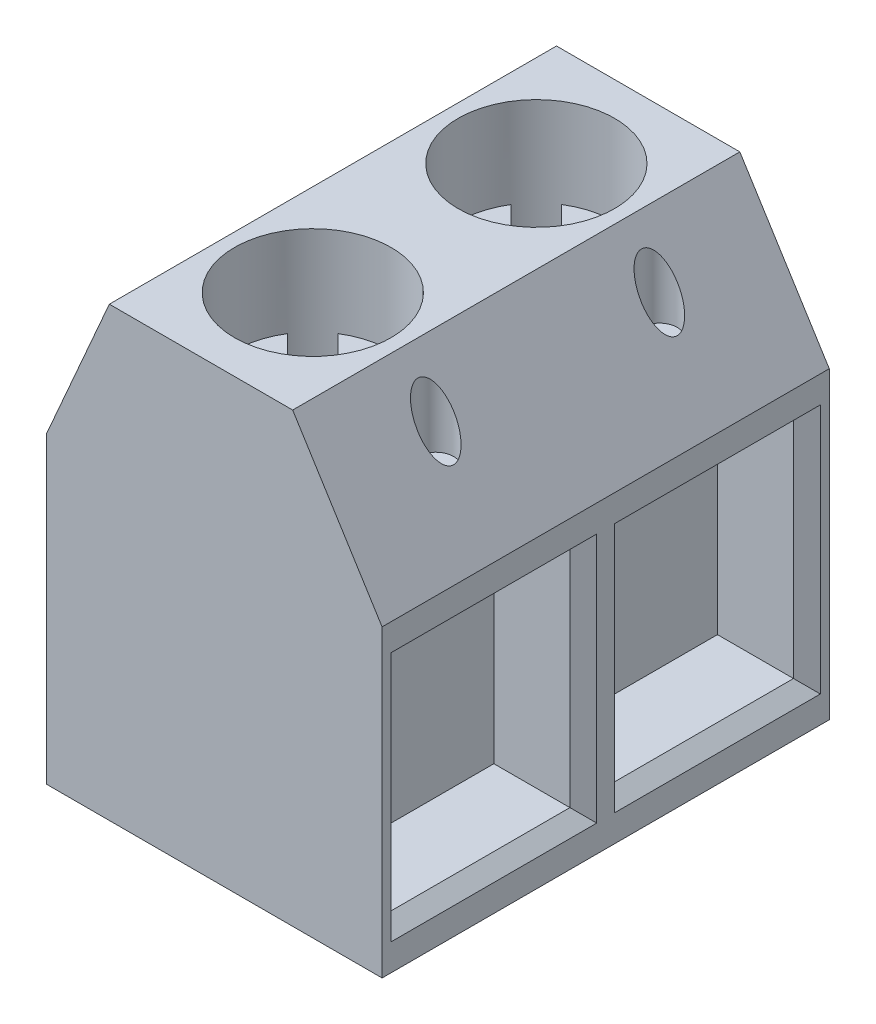
from build123d import *

# Parameters (mm, degrees)
BOSS_EXTRUDE1_DEPTH = 5
SKETCH2_W           = 1
SKETCH2_H           = 1
BOSS_EXTRUDE2_DEPTH = 1
SKETCH3_W           = 4
SKETCH3_H           = 5
CUT_EXTRUDE1_DEPTH  = 2
SKETCH4_R           = 1.75
SKETCH4_R_2         = 0.4
CUT_EXTRUDE2_DEPTH  = 2
CUT_EXTRUDE3_DEPTH  = 0.5
CHAMFER1_SIZE       = 0.3


with BuildPart() as part:
    # Sketch1 → Boss-Extrude1 (new body, symmetric)
    with BuildSketch(Plane.XY):
        Polygon((-3.75, 0), (3.75, 0), (3.75, 6.8), (1.75, 10), (-2.35, 10), (-3.75, 6.8), align=None)
    extrude(amount=BOSS_EXTRUDE1_DEPTH, both=True)

    # Sketch2 → Boss-Extrude2 (add)
    with BuildSketch(Plane.XZ):
        with Locations((0.45, 2.5)):
            Rectangle(SKETCH2_W, SKETCH2_H)
        with Locations((0.45, -2.5)):
            Rectangle(SKETCH2_W, SKETCH2_H)
    extrude(amount=BOSS_EXTRUDE2_DEPTH)

    # Sketch3 → Cut-Extrude1 (cut)
    with BuildSketch(Plane(origin=(3.75, 0, 0), x_dir=(0, 0, -1), z_dir=(1, 0, 0))):
        with Locations((-2.5, 3.4)):
            Rectangle(SKETCH3_W, SKETCH3_H)
        with Locations((2.5, 3.4)):
            Rectangle(SKETCH3_W, SKETCH3_H)
    extrude(amount=-CUT_EXTRUDE1_DEPTH, mode=Mode.SUBTRACT)

    # Sketch4 → Cut-Extrude2 (cut)
    with BuildSketch(Plane(origin=(0, 10, 0), x_dir=(1, 0, 0), z_dir=(0, 1, 0))):
        with Locations((-0.3, 2.5)):
            Circle(SKETCH4_R)
        with Locations((-0.3, -2.5)):
            Circle(SKETCH4_R)
        with Locations((2.45, 2.5)):
            Circle(SKETCH4_R_2)
        with Locations((2.45, -2.5)):
            Circle(SKETCH4_R_2)
        with Locations((-3.05, 2.5)):
            Circle(SKETCH4_R_2)
        with Locations((-3.05, -2.5)):
            Circle(SKETCH4_R_2)
    extrude(amount=-CUT_EXTRUDE2_DEPTH, mode=Mode.SUBTRACT)

    # Sketch5 → Cut-Extrude3 (cut)
    with BuildSketch(Plane(origin=(0, 8, 0), x_dir=(1, 0, 0), z_dir=(0, 1, 0))):
        with BuildLine():
            Line((-1.221836, -1.012479), (-0.3, -1.934315))
            Line((-0.3, -1.934315), (0.124264, -1.510051))
            Line((0.124264, -1.510051), (0.689949, -2.075736))
            Line((0.689949, -2.075736), (0.265685, -2.5))
            Line((0.265685, -2.5), (1.187521, -3.421836))
            ThreePointArc((1.187521, -3.421836), (0.937437, -3.737437), (0.621836, -3.987521))
            Line((0.621836, -3.987521), (-0.3, -3.065685))
            Line((-0.3, -3.065685), (-0.724264, -3.489949))
            Line((-0.724264, -3.489949), (-1.289949, -2.924264))
            Line((-1.289949, -2.924264), (-0.865685, -2.5))
            Line((-0.865685, -2.5), (-1.787521, -1.578164))
            ThreePointArc((-1.787521, -1.578164), (-1.537437, -1.262563), (-1.221836, -1.012479))
        make_face()
        with BuildLine():
            Line((-1.221836, 3.987521), (-0.3, 3.065685))
            Line((-0.3, 3.065685), (0.124264, 3.489949))
            Line((0.124264, 3.489949), (0.689949, 2.924264))
            Line((0.689949, 2.924264), (0.265685, 2.5))
            Line((0.265685, 2.5), (1.187521, 1.578164))
            ThreePointArc((1.187521, 1.578164), (0.937437, 1.262563), (0.621836, 1.012479))
            Line((0.621836, 1.012479), (-0.3, 1.934315))
            Line((-0.3, 1.934315), (-0.724264, 1.510051))
            Line((-0.724264, 1.510051), (-1.289949, 2.075736))
            Line((-1.289949, 2.075736), (-0.865685, 2.5))
            Line((-0.865685, 2.5), (-1.787521, 3.421836))
            ThreePointArc((-1.787521, 3.421836), (-1.537437, 3.737437), (-1.221836, 3.987521))
        make_face()
        with BuildLine():
            Line((-1.221836, -6.012479), (-0.3, -6.934315))
            Line((-0.3, -6.934315), (0.124264, -6.510051))
            Line((0.124264, -6.510051), (0.689949, -7.075736))
            Line((0.689949, -7.075736), (0.265685, -7.5))
            Line((0.265685, -7.5), (1.187521, -8.421836))
            ThreePointArc((1.187521, -8.421836), (0.937437, -8.737437), (0.621836, -8.987521))
            Line((0.621836, -8.987521), (-0.3, -8.065685))
            Line((-0.3, -8.065685), (-0.724264, -8.489949))
            Line((-0.724264, -8.489949), (-1.289949, -7.924264))
            Line((-1.289949, -7.924264), (-0.865685, -7.5))
            Line((-0.865685, -7.5), (-1.787521, -6.578164))
            ThreePointArc((-1.787521, -6.578164), (-1.537437, -6.262563), (-1.221836, -6.012479))
        make_face()
    extrude(amount=-CUT_EXTRUDE3_DEPTH, mode=Mode.SUBTRACT)

    # Chamfer1
    chamfer1_edges = [part.edges().sort_by_distance(p)[0] for p in [
        (3.75, 3.4, 4.5),
        (3.75, 0.9, 2.5),
        (3.75, 3.4, 0.5),
        (3.75, 5.9, 2.5),
        (3.75, 3.4, -0.5),
        (3.75, 0.9, -2.5),
        (3.75, 3.4, -4.5),
        (3.75, 5.9, -2.5),
    ]]
    chamfer(chamfer1_edges, length=CHAMFER1_SIZE)


solid = part.part
